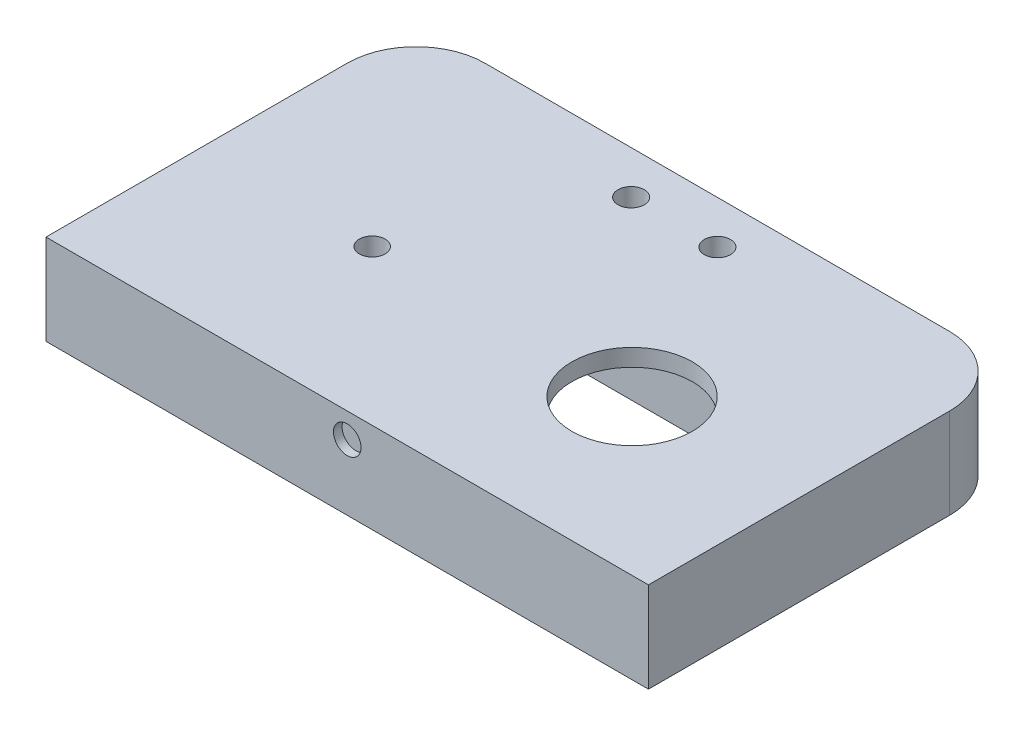
from build123d import *

# Parameters (mm, degrees)
SKETCH_1_W          = 70
SKETCH_1_H          = 43
EXTRUDE_1_DEPTH     = 10.5
SKETCH_2_R          = 1.5
CUT_EXTRUDE_1_DEPTH = 15
SKETCH_3_W          = 41
SKETCH_3_H          = 20.2
CUT_EXTRUDE_2_DEPTH = 6
SKETCH_4_R          = 7
CUT_EXTRUDE_3_DEPTH = 8.5
SKETCH_6_W          = 39
SKETCH_6_H          = 20.2
CUT_EXTRUDE_4_DEPTH = 2.5
SKETCH_7_R          = 1.525
CUT_EXTRUDE_5_DEPTH = 5
SKETCH_9_W          = 55
SKETCH_9_H          = 1.8
CUT_EXTRUDE_6_DEPTH = 2
FILLET_1_R          = 8
SKETCH_10_R         = 7
SKETCH_10_R_2       = 1.5
SKETCH_10_R_3       = 1.525
CUT_EXTRUDE_7_DEPTH = 20
SKETCH_11_R         = 1.6
CUT_EXTRUDE_8_DEPTH = 1


with BuildPart() as part:
    # 草图1 → 凸台-拉伸1 (new body)
    with BuildSketch(Plane(origin=(0, 0, 0), x_dir=(1, 0, 0), z_dir=(0, 1, 0))):
        with Locations((0, 3.5)):
            Rectangle(SKETCH_1_W, SKETCH_1_H)
    extrude(amount=EXTRUDE_1_DEPTH)

    # 草图2 → 切除-拉伸1 (cut)
    with BuildSketch(Plane(origin=(0, 10.5, 0), x_dir=(1, 0, 0), z_dir=(0, 1, 0))):
        with Locations((15.1, 0)):
            Circle(SKETCH_2_R)
        with Locations((-15.1, 0)):
            Circle(SKETCH_2_R)
    extrude(amount=-CUT_EXTRUDE_1_DEPTH, mode=Mode.SUBTRACT)

    # 草图3 → 切除-拉伸2 (cut)
    with BuildSketch(Plane.XZ):
        with Locations((5.1, 0)):
            Rectangle(SKETCH_3_W, SKETCH_3_H)
    extrude(amount=-CUT_EXTRUDE_2_DEPTH, mode=Mode.SUBTRACT)

    # 草图4 → 切除-拉伸3 (cut)
    with BuildSketch(Plane.XZ.offset(-6)):
        with Locations((15.1, 0)):
            Circle(SKETCH_4_R)
    extrude(amount=-CUT_EXTRUDE_3_DEPTH, mode=Mode.SUBTRACT)

    # 草图6 → 切除-拉伸4 (cut)
    with BuildSketch(Plane.XZ.offset(-6)):
        with Locations((6.1, 0)):
            Rectangle(SKETCH_6_W, SKETCH_6_H)
    extrude(amount=-CUT_EXTRUDE_4_DEPTH, mode=Mode.SUBTRACT)

    # 草图7 → 切除-拉伸5 (cut)
    with BuildSketch(Plane.XZ):
        with Locations((29.2, 5)):
            Circle(SKETCH_7_R)
        with Locations((29.2, -5)):
            Circle(SKETCH_7_R)
        with Locations((-19, -5)):
            Circle(SKETCH_7_R)
        with Locations((-19, 5)):
            Circle(SKETCH_7_R)
    extrude(amount=-CUT_EXTRUDE_5_DEPTH, mode=Mode.SUBTRACT)

    # 草图9 → 切除-拉伸6 (cut)
    with BuildSketch(Plane.XZ):
        with Locations((5.1, 0)):
            Rectangle(SKETCH_9_W, SKETCH_9_H)
    extrude(amount=-CUT_EXTRUDE_6_DEPTH, mode=Mode.SUBTRACT)

    # 圆角1
    fillet_1_edges = [part.edges().sort_by_distance(p)[0] for p in [
        (-35, 5.25, -25),
        (35, 5.25, -25),
    ]]
    fillet(fillet_1_edges, radius=FILLET_1_R)

    # 草图10 → 切除-拉伸7 (cut)
    with BuildSketch(Plane(origin=(0, 10.5, 0), x_dir=(1, 0, 0), z_dir=(0, 1, 0))):
        with Locations((15.1, 0)):
            Circle(SKETCH_10_R)
        with Locations((-15.1, 0)):
            Circle(SKETCH_10_R_2)
        with Locations((-5.01238383, 20)):
            Circle(SKETCH_10_R_3)
        with Locations((5.01238383, 20)):
            Circle(SKETCH_10_R_3)
    extrude(amount=-CUT_EXTRUDE_7_DEPTH, mode=Mode.SUBTRACT)

    # 草图11 → 切除-拉伸8 (cut)
    with BuildSketch(Plane.XY.offset(18)):
        with Locations((0, 7.607443484)):
            Circle(SKETCH_11_R)
    extrude(amount=-CUT_EXTRUDE_8_DEPTH, mode=Mode.SUBTRACT)


solid = part.part
